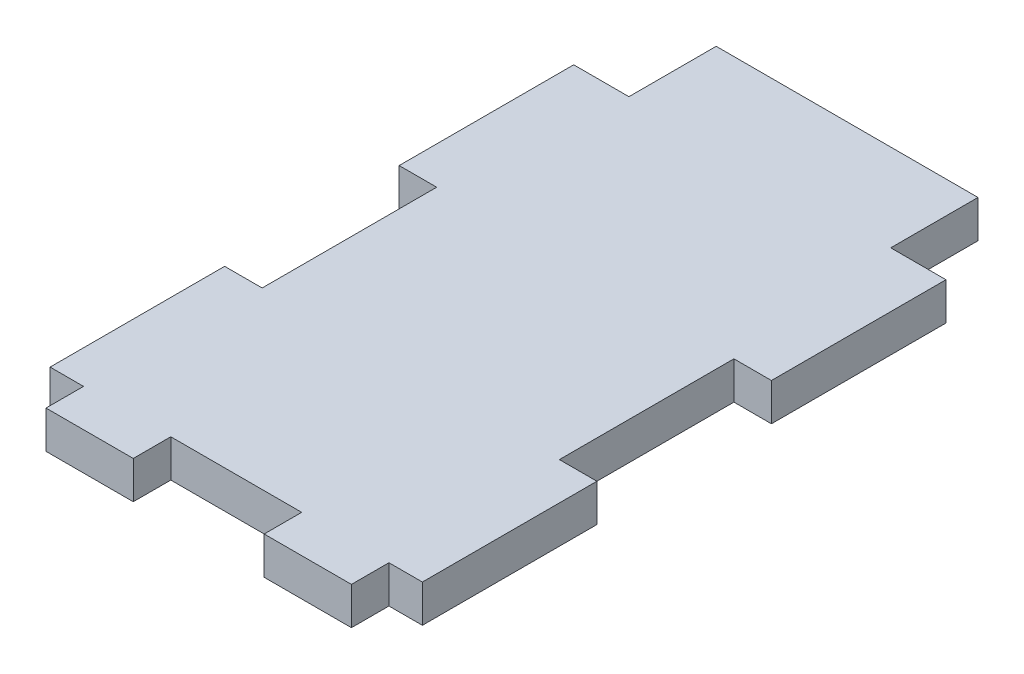
from build123d import *

# Parameters (mm, degrees)
SKETCH1_W           = 54.1782
SKETCH1_H           = 76.2
BOSS_EXTRUDE1_DEPTH = 5.461
SKETCH2_W           = 12.7
SKETCH2_H           = 5.461
SKETCH2_W_2         = 38.1
SKETCH2_H_2         = 12.7
BOSS_EXTRUDE2_DEPTH = 5.461
SKETCH3_W           = 5.461
SKETCH3_H           = 25.4
CUT_EXTRUDE1_DEPTH  = 6.461


with BuildPart() as part:
    # Sketch1 → Boss-Extrude1 (new body)
    with BuildSketch(Plane(origin=(0, 0, 0), x_dir=(1, 0, 0), z_dir=(0, 1, 0))):
        Rectangle(SKETCH1_W, SKETCH1_H)
    extrude(amount=BOSS_EXTRUDE1_DEPTH)

    # Sketch2 → Boss-Extrude2 (add)
    with BuildSketch(Plane(origin=(0, 5.461, 0), x_dir=(1, 0, 0), z_dir=(0, 1, 0))):
        with Locations((-15.875, -40.8305)):
            Rectangle(SKETCH2_W, SKETCH2_H)
        with Locations((15.875, -40.8305)):
            Rectangle(SKETCH2_W, SKETCH2_H)
        with Locations((0, 44.45)):
            Rectangle(SKETCH2_W_2, SKETCH2_H_2)
    extrude(amount=-BOSS_EXTRUDE2_DEPTH)

    # Sketch3 → Cut-Extrude1 (cut, through all)
    with BuildSketch(Plane(origin=(0, 5.461, 0), x_dir=(1, 0, 0), z_dir=(0, 1, 0))):
        with Locations((-24.3586, 0)):
            Rectangle(SKETCH3_W, SKETCH3_H)
        with Locations((24.3586, 0)):
            Rectangle(SKETCH3_W, SKETCH3_H)
    extrude(amount=-CUT_EXTRUDE1_DEPTH, mode=Mode.SUBTRACT)


solid = part.part
